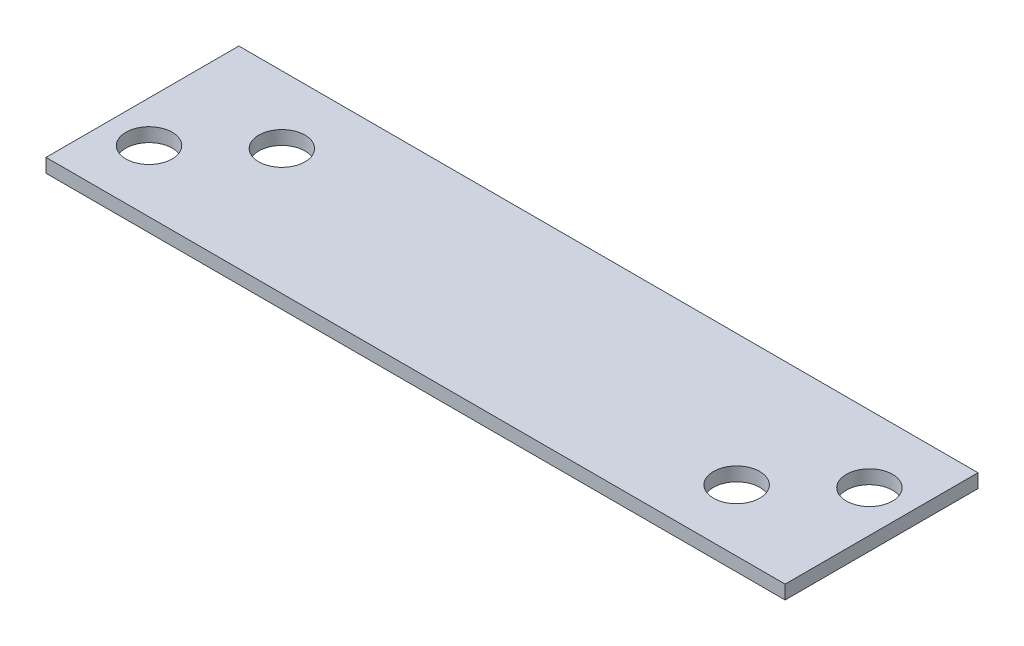
from build123d import *

# Parameters (mm, degrees)
SKETCH1_W           = 85.1662
SKETCH1_H           = 22.225
BOSS_EXTRUDE1_DEPTH = 1.5875
CUT_EXTRUDE1_REACH  = 3.587
SKETCH2_R           = 2.667


with BuildPart() as part:
    # Sketch1 → Boss-Extrude1 (new body)
    with BuildSketch(Plane(origin=(0, 0, 0), x_dir=(1, 0, 0), z_dir=(0, 1, 0))):
        with Locations((42.5831, 11.1125)):
            Rectangle(SKETCH1_W, SKETCH1_H)
    extrude(amount=BOSS_EXTRUDE1_DEPTH)

    # Sketch2 → Cut-Extrude1 (cut, up to next)
    with BuildSketch(Plane.XZ, mode=Mode.PRIVATE) as cut_extrude1_sk1:
        with Locations((4.7625, -7.112)):
            Circle(SKETCH2_R)
    cut_extrude1_tool1 = extrude(cut_extrude1_sk1.sketch, amount=-CUT_EXTRUDE1_REACH, mode=Mode.PRIVATE) & part.part
    add(cut_extrude1_tool1.solids().sort_by_distance((4.7625, 0, -7.112))[0], mode=Mode.SUBTRACT)
    # Sketch2 → Cut-Extrude1 (cut, up to next)
    with BuildSketch(Plane.XZ, mode=Mode.PRIVATE) as cut_extrude1_sk2:
        with Locations((12.7, -14.478)):
            Circle(SKETCH2_R)
    cut_extrude1_tool2 = extrude(cut_extrude1_sk2.sketch, amount=-CUT_EXTRUDE1_REACH, mode=Mode.PRIVATE) & part.part
    add(cut_extrude1_tool2.solids().sort_by_distance((12.7, 0, -14.478))[0], mode=Mode.SUBTRACT)
    # Sketch2 → Cut-Extrude1 (cut, up to next)
    with BuildSketch(Plane.XZ, mode=Mode.PRIVATE) as cut_extrude1_sk3:
        with Locations((72.4662, -7.112)):
            Circle(SKETCH2_R)
    cut_extrude1_tool3 = extrude(cut_extrude1_sk3.sketch, amount=-CUT_EXTRUDE1_REACH, mode=Mode.PRIVATE) & part.part
    add(cut_extrude1_tool3.solids().sort_by_distance((72.4662, 0, -7.112))[0], mode=Mode.SUBTRACT)
    # Sketch2 → Cut-Extrude1 (cut, up to next)
    with BuildSketch(Plane.XZ, mode=Mode.PRIVATE) as cut_extrude1_sk4:
        with Locations((80.4037, -14.478)):
            Circle(SKETCH2_R)
    cut_extrude1_tool4 = extrude(cut_extrude1_sk4.sketch, amount=-CUT_EXTRUDE1_REACH, mode=Mode.PRIVATE) & part.part
    add(cut_extrude1_tool4.solids().sort_by_distance((80.4037, 0, -14.478))[0], mode=Mode.SUBTRACT)


solid = part.part
